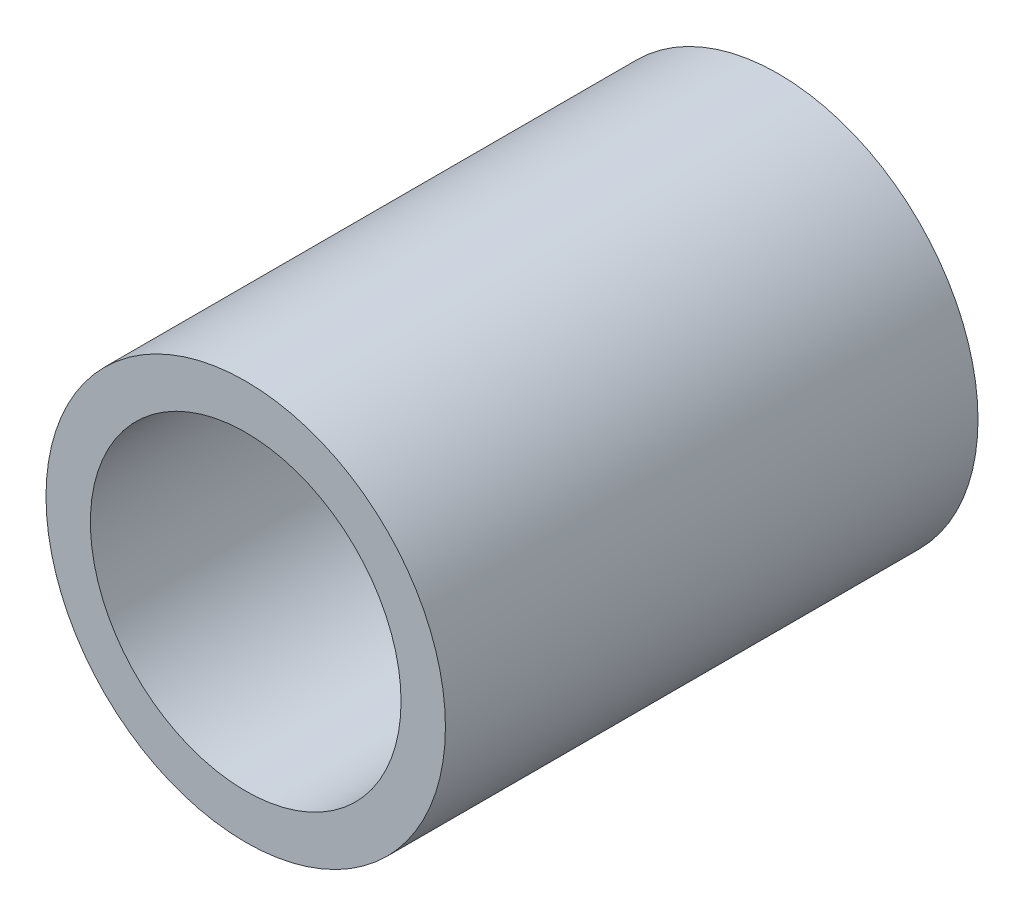
from build123d import *

# Parameters (mm, degrees)
SKETCH1_R           = 27
SKETCH1_R_2         = 21
BOSS_EXTRUDE1_DEPTH = 36


with BuildPart() as part:
    # Sketch1 → Boss-Extrude1 (new body, symmetric)
    with BuildSketch(Plane.XY):
        Circle(SKETCH1_R)
        Circle(SKETCH1_R_2, mode=Mode.SUBTRACT)
    extrude(amount=BOSS_EXTRUDE1_DEPTH, both=True)


solid = part.part
